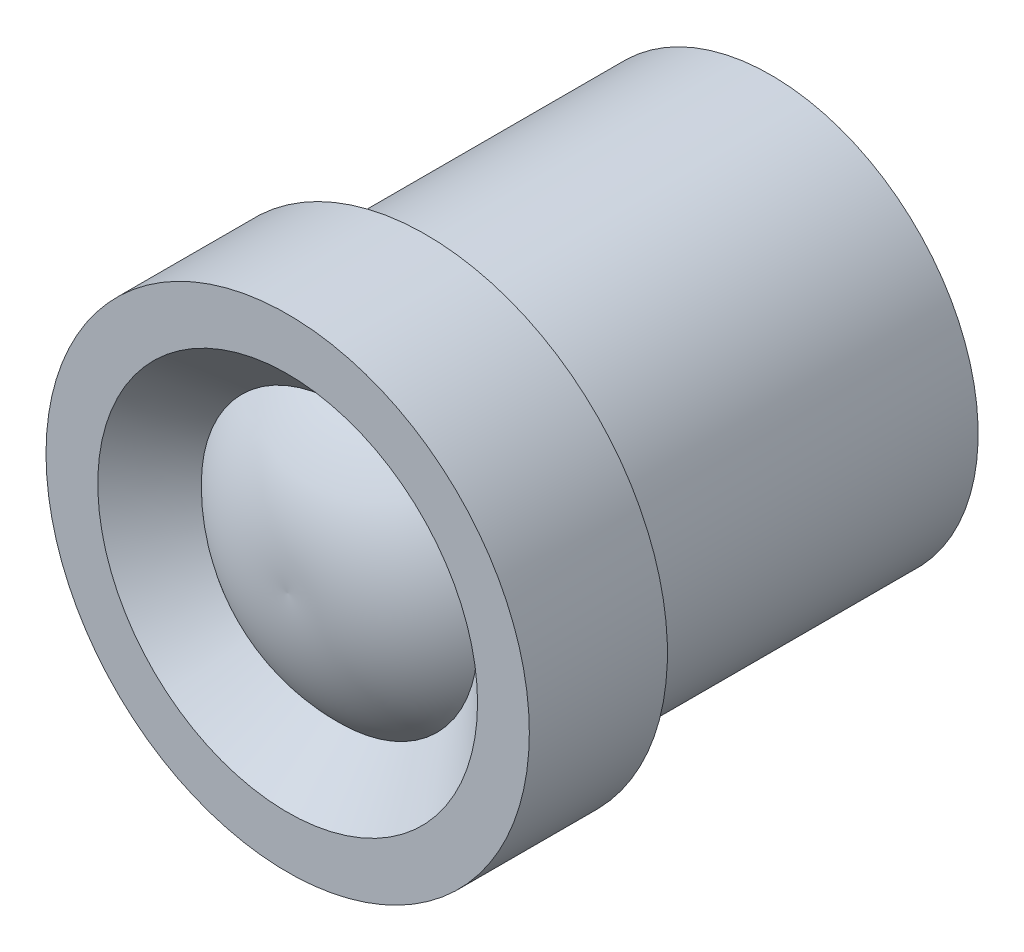
from build123d import *

# Parameters (mm, degrees)
SKETCH1_R           = 7
BOSS_EXTRUDE1_DEPTH = 14
SKETCH2_OUTSIDE_W   = 20.85
SKETCH2_OUTSIDE_H   = 20.85
SKETCH2_OUTSIDE_R   = 6
CUT_EXTRUDE1_DEPTH  = 10
SKETCH3_R           = 5.5
CUT_EXTRUDE2_DEPTH  = 1.5
CUT_EXTRUDE2_TAPER  = 45
SKETCH4_R           = 4
CUT_EXTRUDE3_DEPTH  = 12.5
SKETCH5_R           = 4
BOSS_EXTRUDE3_DEPTH = 12.5


with BuildPart() as part:
    # Sketch1 → Boss-Extrude1 (new body)
    with BuildSketch(Plane.XY):
        Circle(SKETCH1_R)
    extrude(amount=BOSS_EXTRUDE1_DEPTH)

    # Sketch2 outside → Cut-Extrude1 (cut)
    with BuildSketch(Plane(origin=(0, 0, 0), x_dir=(-1, 0, 0), z_dir=(0, 0, -1))):
        Rectangle(SKETCH2_OUTSIDE_W, SKETCH2_OUTSIDE_H)
        Circle(SKETCH2_OUTSIDE_R, mode=Mode.SUBTRACT)
    extrude(amount=-CUT_EXTRUDE1_DEPTH, mode=Mode.SUBTRACT)

    # Sketch3 → Cut-Extrude2 (cut)
    with BuildSketch(Plane.XY.offset(14)):
        Circle(SKETCH3_R)
    extrude(amount=-CUT_EXTRUDE2_DEPTH, taper=CUT_EXTRUDE2_TAPER, mode=Mode.SUBTRACT)

    # Sketch4 → Cut-Extrude3 (cut)
    with BuildSketch(Plane.XY.offset(12.5)):
        Circle(SKETCH4_R)
    extrude(amount=-CUT_EXTRUDE3_DEPTH, mode=Mode.SUBTRACT)



with BuildPart() as body_2:
    # Sketch5 → Boss-Extrude3 (new body)
    with BuildSketch(Plane(origin=(0, 0, 0), x_dir=(-1, 0, 0), z_dir=(0, 0, -1))):
        Circle(SKETCH5_R)
    extrude(amount=-BOSS_EXTRUDE3_DEPTH)


with BuildPart() as part_1:
    add(part.part)

    add(body_2.part)  # Revolve1 merges body 2
    # Sketch6 → Revolve1 (revolve)
    with BuildSketch(Plane(origin=(0, 0, 0), x_dir=(1, 0, 0), z_dir=(0, 1, 0))):
        with BuildLine():
            Line((-4, -12.5), (0, -12.5))
            Line((0, -12.5), (0, -14))
            ThreePointArc((0, -14), (-2.168263504, -13.698702678), (-4, -12.5))
        make_face()
    revolve(axis=Axis((0, 0, 12.5), (0, 0, 1)))


solid = part_1.part
